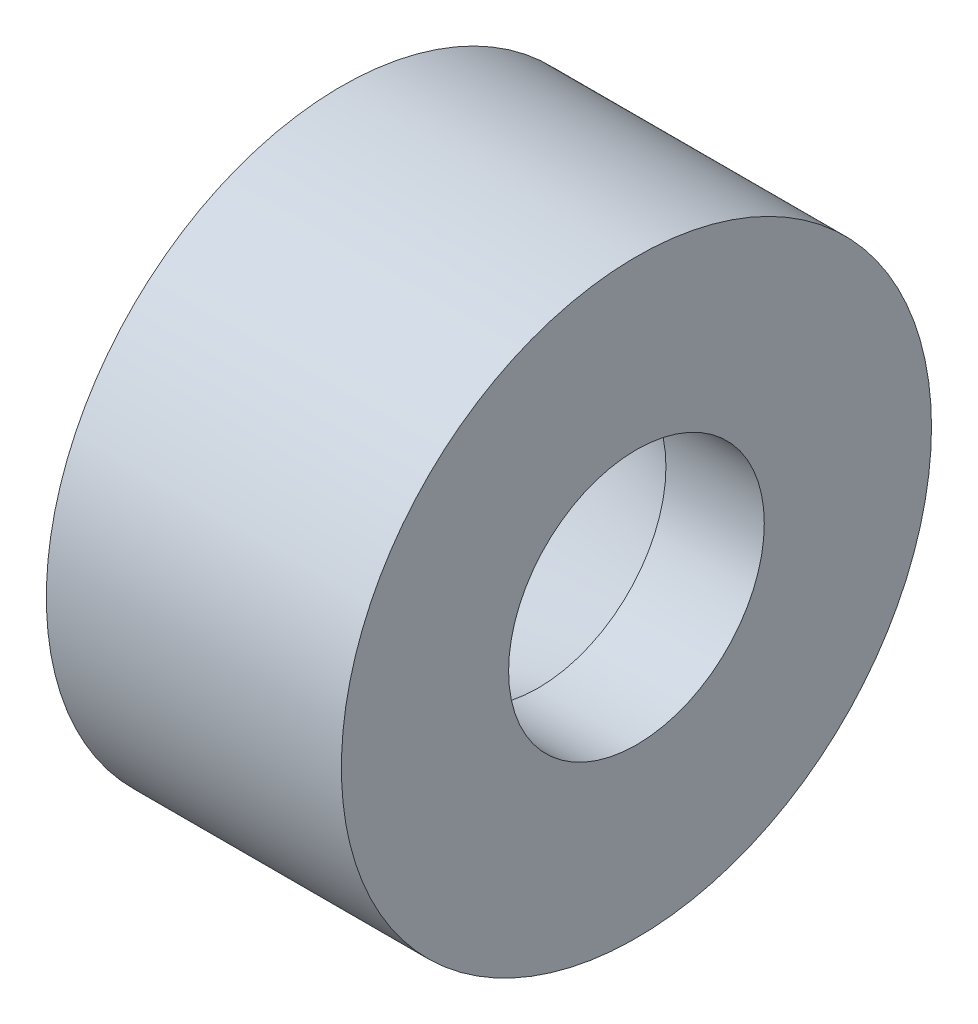
from build123d import *


with BuildPart() as part:
    # Schizzo1 → Rivoluzione1 (revolve)
    with BuildSketch(Plane.XY):
        Polygon((0, 6.5), (-5, 6.5), (-15, 10.139702343), (-15, 15), (0, 15), align=None)
    revolve(axis=Axis((0, 0, 0), (-1, 0, 0)))


solid = part.part
